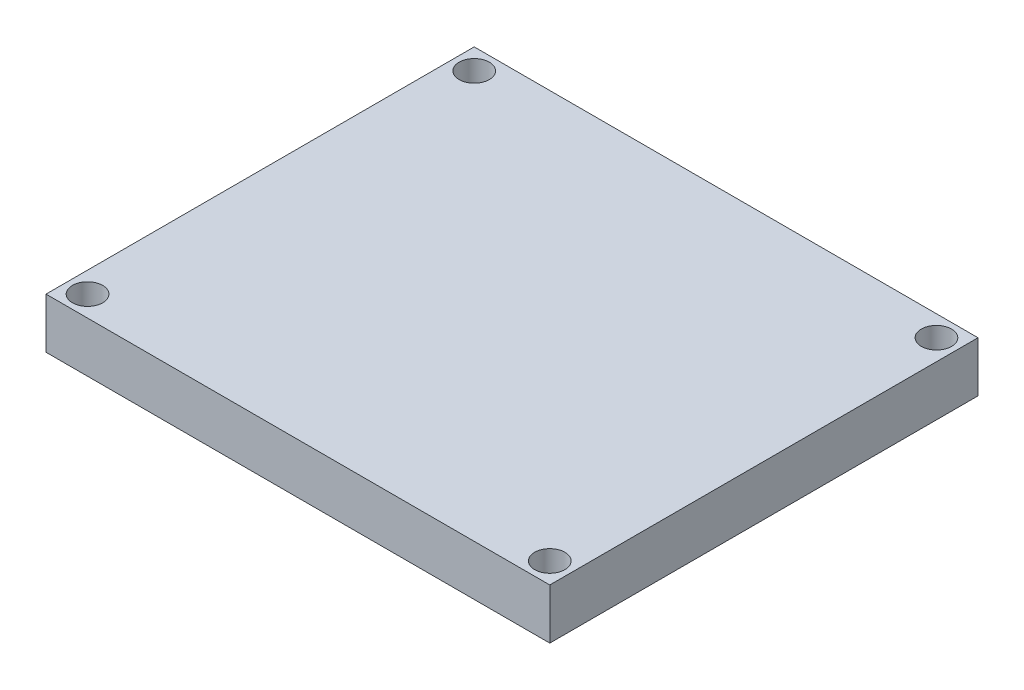
from build123d import *

# Parameters (mm, degrees)
SKETCH1_W           = 50.8
SKETCH1_H           = 43.18
SKETCH1_R           = 1.524
BOSS_EXTRUDE1_DEPTH = 5.08


with BuildPart() as part:
    # Sketch1 → Boss-Extrude1 (new body)
    with BuildSketch(Plane(origin=(0, 0, 0), x_dir=(1, 0, 0), z_dir=(0, 1, 0))):
        Rectangle(SKETCH1_W, SKETCH1_H)
        with Locations(Location((-23.3045, 19.4945, 0), (0, 0, 270))):  # turned: the seam where the file's is
            Circle(SKETCH1_R, mode=Mode.SUBTRACT)
        with Locations(Location((23.3045, 19.4945, 0), (0, 0, 270))):  # turned: the seam where the file's is
            Circle(SKETCH1_R, mode=Mode.SUBTRACT)
        with Locations(Location((-23.3045, -19.4945, 0), (0, 0, 270))):  # turned: the seam where the file's is
            Circle(SKETCH1_R, mode=Mode.SUBTRACT)
        with Locations(Location((23.3045, -19.4945, 0), (0, 0, 270))):  # turned: the seam where the file's is
            Circle(SKETCH1_R, mode=Mode.SUBTRACT)
    extrude(amount=BOSS_EXTRUDE1_DEPTH)


solid = part.part
